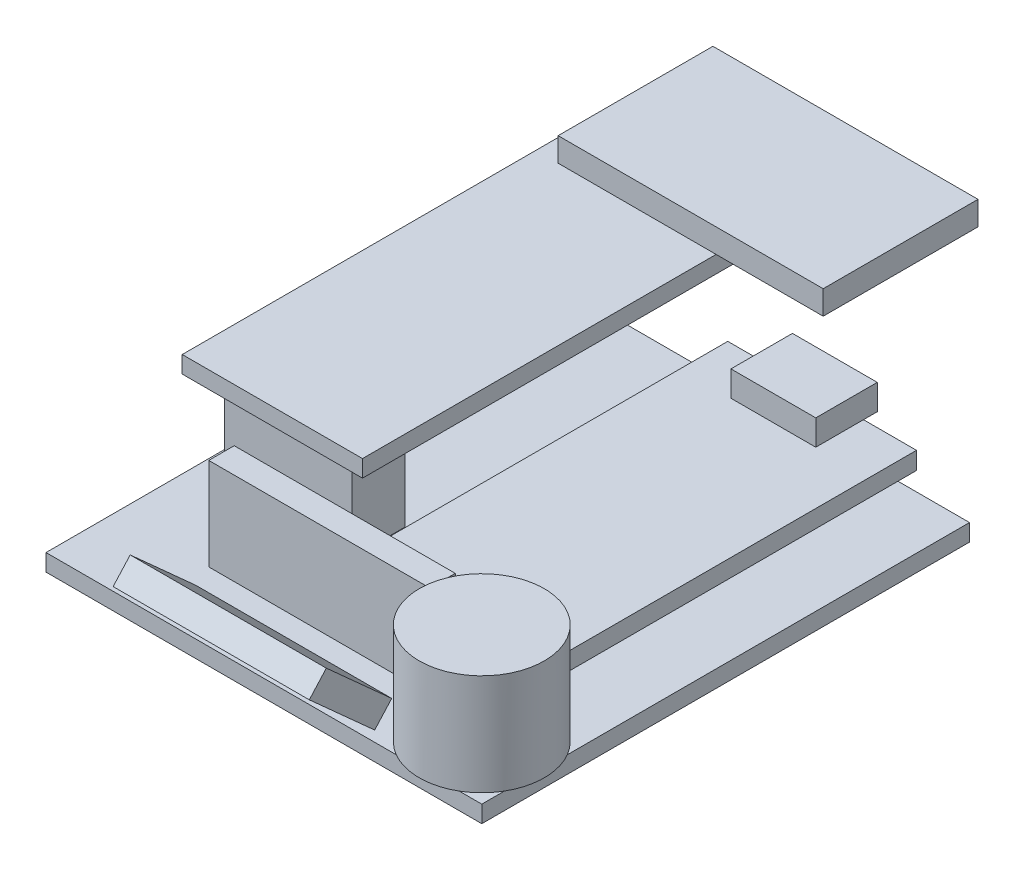
from build123d import *

# Parameters (mm, degrees)
SKETCH1_W            = 41.1
SKETCH1_H            = 46
BOSS_EXTRUDE1_DEPTH  = 1.6
SKETCH2_R            = 5.9
BOSS_EXTRUDE2_DEPTH  = 9.55
BOSS_EXTRUDE3_START  = 2.75
SKETCH3_W            = 17.8
SKETCH3_H            = 33.1
BOSS_EXTRUDE3_DEPTH  = 1.65
SKETCH4_W            = 8
SKETCH4_H            = 5.8
BOSS_EXTRUDE4_DEPTH  = 2.4
SKETCH5_W            = 12
SKETCH5_H            = 5
BOSS_EXTRUDE5_DEPTH  = 8.5
SKETCH7_W            = 20.85
SKETCH7_H            = 2.4
BOSS_EXTRUDE7_DEPTH  = 8.7
BOSS_EXTRUDE8_START  = -11.5
BOSS_EXTRUDE8_DEPTH  = 18.5
SKETCH9_W            = 17
SKETCH9_H            = 46
BOSS_EXTRUDE10_DEPTH = 1.6
BOSS_EXTRUDE11_START = 0.7
SKETCH6_W            = 25
SKETCH6_H            = 14.6
BOSS_EXTRUDE11_DEPTH = 2.25


with BuildPart() as part:
    # Sketch1 → Boss-Extrude1 (new body)
    with BuildSketch(Plane(origin=(0, 0, 0), x_dir=(1, 0, 0), z_dir=(0, 1, 0))):
        with Locations((11.547619734, -3.511008705)):
            Rectangle(SKETCH1_W, SKETCH1_H)
    extrude(amount=BOSS_EXTRUDE1_DEPTH)

    # Sketch2 → Boss-Extrude2 (add)
    with BuildSketch(Plane(origin=(0, 1.6, 0), x_dir=(1, 0, 0), z_dir=(0, 1, 0))):
        with Locations((26.997619734, -21.411008705)):
            Circle(SKETCH2_R)
    extrude(amount=BOSS_EXTRUDE2_DEPTH)

    # Sketch5 → Boss-Extrude5 (add)
    with BuildSketch(Plane(origin=(0, 1.6, 0), x_dir=(1, 0, 0), z_dir=(0, 1, 0))):
        with Locations((-0.152380266, -10.011008705)):
            Rectangle(SKETCH5_W, SKETCH5_H)
    extrude(amount=BOSS_EXTRUDE5_DEPTH)

    # Sketch7 → Boss-Extrude7 (add)
    with BuildSketch(Plane(origin=(0, 1.6, 0), x_dir=(1, 0, 0), z_dir=(0, 1, 0))):
        with Locations((10.272619734, -18.811008705)):
            Rectangle(SKETCH7_W, SKETCH7_H)
    extrude(amount=BOSS_EXTRUDE7_DEPTH)

    # Sketch9 → Boss-Extrude10 (add)
    with BuildSketch(Plane(origin=(0, 10.1, 0), x_dir=(1, 0, 0), z_dir=(0, 1, 0))):
        with Locations((-0.152380266, 8.988991295)):
            Rectangle(SKETCH9_W, SKETCH9_H)
    extrude(amount=BOSS_EXTRUDE10_DEPTH)


with BuildPart() as body_2:
    # Sketch3 → Boss-Extrude3 (new body)
    with BuildSketch(Plane(origin=(0, 1.6, 0), x_dir=(1, 0, 0), z_dir=(0, 1, 0)).offset(BOSS_EXTRUDE3_START)):
        with Locations((19.197619734, 1.938991295)):
            Rectangle(SKETCH3_W, SKETCH3_H)
    extrude(amount=BOSS_EXTRUDE3_DEPTH)

    # Sketch4 → Boss-Extrude4 (add)
    with BuildSketch(Plane(origin=(0, 6, 0), x_dir=(1, 0, 0), z_dir=(0, 1, 0))):
        with Locations((19.097619734, 16.888991295)):
            Rectangle(SKETCH4_W, SKETCH4_H)
    extrude(amount=BOSS_EXTRUDE4_DEPTH)


with BuildPart() as body_3:
    # Sketch8 → Boss-Extrude8 (new body)
    with BuildSketch(Plane.ZY.offset(9.002380266).offset(BOSS_EXTRUDE8_START)):
        Polygon((23.905095249, 3.383547581), (30.073197301, 8.937331614), (31.679110756, 7.153784033), (25.511008705, 1.6), align=None)
    extrude(amount=-BOSS_EXTRUDE8_DEPTH)


with BuildPart() as body_4:
    # Sketch6 → Boss-Extrude11 (new body)
    with BuildSketch(Plane(origin=(0, 11.7, 0), x_dir=(1, 0, 0), z_dir=(0, 1, 0)).offset(BOSS_EXTRUDE11_START)):
        with Locations((6.647619734, 25.938991295)):
            Rectangle(SKETCH6_W, SKETCH6_H)
    extrude(amount=BOSS_EXTRUDE11_DEPTH)


solid = Compound([part.part, body_2.part, body_3.part, body_4.part])
